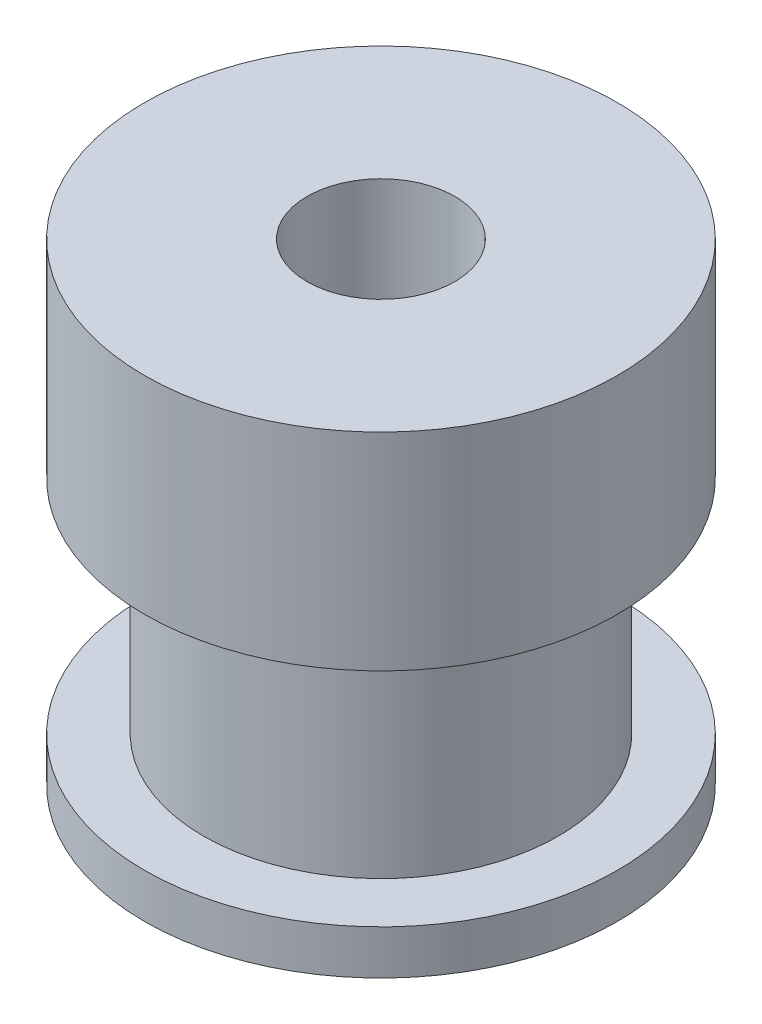
from build123d import *

# Parameters (mm, degrees)
SKETCH1_R           = 8
SKETCH1_R_2         = 2.5
BOSS_EXTRUDE1_DEPTH = 16
CUT_EXTRUDE1_START  = -7
SKETCH2_R           = 8
SKETCH2_R_2         = 6
CUT_EXTRUDE1_DEPTH  = 7.5


with BuildPart() as part:
    # Sketch1 → Boss-Extrude1 (new body)
    with BuildSketch(Plane(origin=(0, 0, 0), x_dir=(1, 0, 0), z_dir=(0, 1, 0))):
        Circle(SKETCH1_R)
        Circle(SKETCH1_R_2, mode=Mode.SUBTRACT)
    extrude(amount=BOSS_EXTRUDE1_DEPTH)

    # Sketch2 → Cut-Extrude1 (cut)
    with BuildSketch(Plane(origin=(0, 16, 0), x_dir=(1, 0, 0), z_dir=(0, 1, 0)).offset(CUT_EXTRUDE1_START)):
        Circle(SKETCH2_R)
        Circle(SKETCH2_R_2, mode=Mode.SUBTRACT)
    extrude(amount=-CUT_EXTRUDE1_DEPTH, mode=Mode.SUBTRACT)


solid = part.part
